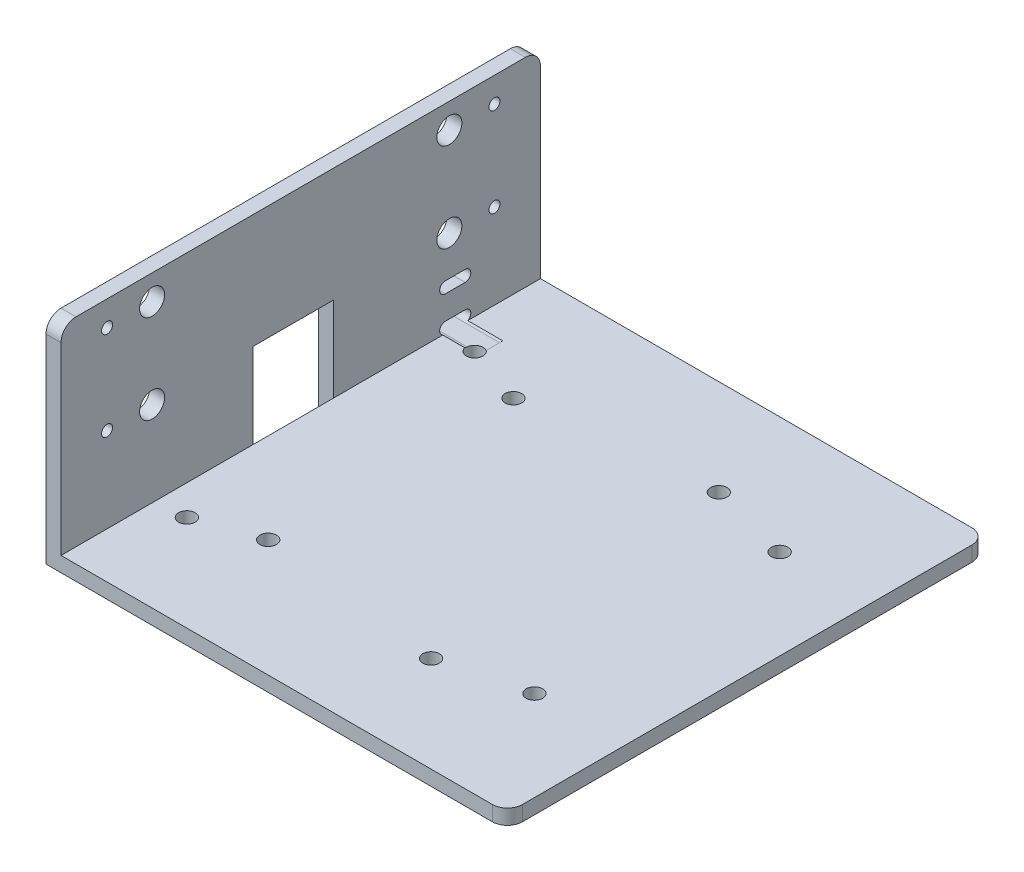
from build123d import *

# Parameters (mm, degrees)
SKETCH_3_W           = 89.2
SKETCH_3_H           = 95.8
SKETCH_3_R           = 1.65
EXTRUDE_1_DEPTH      = 3
EXTRUDE_1_DEPTH_BACK = 0.0001
SKETCH_6_W           = 3
SKETCH_6_H           = 95.8
EXTRUDE_3_DEPTH      = 42.8
SKETCH_8_R           = 1.1
CUT_EXTRUDE_6_DEPTH  = 47.8
SKETCH_8_9_R         = 1.1
CUT_EXTRUDE_7_DEPTH  = 47.8
SKETCH_8_10_R        = 1.1
CUT_EXTRUDE_8_DEPTH  = 47.8
SKETCH_8_11_R        = 1.1
CUT_EXTRUDE_9_DEPTH  = 47.8
SKETCH_12_R          = 2.5
CUT_EXTRUDE_10_DEPTH = 47.8
SKETCH_12_4_R        = 2.5
CUT_EXTRUDE_11_DEPTH = 47.8
CUT_EXTRUDE_21_DEPTH = 19.978934005
SKETCH_16_W          = 3
SKETCH_16_H          = 16.067623689
EXTRUDE_4_DEPTH      = 3
SKETCH_17_W          = 16.067623689
SKETCH_17_H          = 3
CUT_EXTRUDE_22_DEPTH = 3
CUT_EXTRUDE_23_DEPTH = 10
FILLET_1_R           = 3
FILLET_2_R           = 3
FILLET_3_R           = 3
FILLET_4_R           = 3


with BuildPart() as part:
    # Sketch 3 → Extrude 1 (new body, two sides)
    with BuildSketch(Plane(origin=(0, 0, 0), x_dir=(1, 0, 0), z_dir=(0, 1, 0))) as extrude_1_sk:
        with Locations((44.6, -47.9)):
            Rectangle(SKETCH_3_W, SKETCH_3_H)
        with Locations(Location((18, -23.4, 0), (0, 0, 270))):  # turned: the seam where the file's is
            Circle(SKETCH_3_R, mode=Mode.SUBTRACT)
        with Locations(Location((71.2, -23.4, 0), (0, 0, 270))):  # turned: the seam where the file's is
            Circle(SKETCH_3_R, mode=Mode.SUBTRACT)
        with Locations(Location((18, -72.4, 0), (0, 0, 270))):  # turned: the seam where the file's is
            Circle(SKETCH_3_R, mode=Mode.SUBTRACT)
        with Locations(Location((71.2, -72.4, 0), (0, 0, 270))):  # turned: the seam where the file's is
            Circle(SKETCH_3_R, mode=Mode.SUBTRACT)
        with Locations(Location((6, -19.15, 0), (0, 0, 270))):  # turned: the seam where the file's is
            Circle(SKETCH_3_R, mode=Mode.SUBTRACT)
        with Locations(Location((54.8, -19.15, 0), (0, 0, 270))):  # turned: the seam where the file's is
            Circle(SKETCH_3_R, mode=Mode.SUBTRACT)
        with Locations(Location((6, -76.65, 0), (0, 0, 270))):  # turned: the seam where the file's is
            Circle(SKETCH_3_R, mode=Mode.SUBTRACT)
        with Locations(Location((54.8, -76.65, 0), (0, 0, 270))):  # turned: the seam where the file's is
            Circle(SKETCH_3_R, mode=Mode.SUBTRACT)
    extrude(amount=EXTRUDE_1_DEPTH)
    extrude(extrude_1_sk.sketch, amount=-EXTRUDE_1_DEPTH_BACK)

    # Sketch 6 → Extrude 3 (add)
    with BuildSketch(Plane.XZ.offset(0.0001)):
        with Locations((-1.5, 47.9)):
            Rectangle(SKETCH_6_W, SKETCH_6_H)
    extrude(amount=-EXTRUDE_3_DEPTH)

    # Sketch 8 → Cut-Extrude 6 (cut)
    with BuildSketch(Plane.ZY.offset(3)):
        with Locations((86.6, 37.8)):
            Circle(SKETCH_8_R)
    extrude(amount=-CUT_EXTRUDE_6_DEPTH, mode=Mode.SUBTRACT)

    # Sketch 8_9 → Cut-Extrude 7 (cut)
    with BuildSketch(Plane.ZY.offset(3)):
        with Locations((9.2, 37.8)):
            Circle(SKETCH_8_9_R)
    extrude(amount=-CUT_EXTRUDE_7_DEPTH, mode=Mode.SUBTRACT)

    # Sketch 8_10 → Cut-Extrude 8 (cut)
    with BuildSketch(Plane.ZY.offset(3)):
        with Locations((9.2, 20)):
            Circle(SKETCH_8_10_R)
    extrude(amount=-CUT_EXTRUDE_8_DEPTH, mode=Mode.SUBTRACT)

    # Sketch 8_11 → Cut-Extrude 9 (cut)
    with BuildSketch(Plane.ZY.offset(3)):
        with Locations((86.6, 20)):
            Circle(SKETCH_8_11_R)
    extrude(amount=-CUT_EXTRUDE_9_DEPTH, mode=Mode.SUBTRACT)

    # Sketch 12 → Cut-Extrude 10 (cut)
    with BuildSketch(Plane.ZY.offset(3)):
        with Locations((18.2, 37.8)):
            Circle(SKETCH_12_R)
    extrude(amount=-CUT_EXTRUDE_10_DEPTH, mode=Mode.SUBTRACT)

    # Sketch 12_4 → Cut-Extrude 11 (cut)
    with BuildSketch(Plane.ZY.offset(3)):
        with Locations((77.6, 37.8)):
            Circle(SKETCH_12_4_R)
        with Locations((77.6, 20)):
            Circle(SKETCH_12_4_R)
        with Locations((18.2, 37.8)):
            Circle(SKETCH_12_4_R)
        with Locations((18.2, 20)):
            Circle(SKETCH_12_4_R)
    extrude(amount=-CUT_EXTRUDE_11_DEPTH, mode=Mode.SUBTRACT)

    # Sketch 13 → Cut-Extrude 21 (cut)
    with BuildSketch(Plane.XZ.offset(0.0001)):
        Polygon((-5, 47.9), (-5, 57.401139719), (0, 57.401139719), (0, 41.33351603), (-5, 41.33351603), align=None)
    extrude(amount=-CUT_EXTRUDE_21_DEPTH, mode=Mode.SUBTRACT)

    # Sketch 16 → Extrude 4 (add)
    with BuildSketch(Plane.XZ.offset(0.0001)):
        with Locations((-1.5, 49.367327875)):
            Rectangle(SKETCH_16_W, SKETCH_16_H)
    extrude(amount=-EXTRUDE_4_DEPTH)

    # Sketch 17 → Cut-Extrude 22 (cut)
    with BuildSketch(Plane.ZY.offset(3)):
        with Locations((49.367327875, 1.4999)):
            Rectangle(SKETCH_17_W, SKETCH_17_H)
    extrude(amount=-CUT_EXTRUDE_22_DEPTH, mode=Mode.SUBTRACT)

    # Sketch 18 → Cut-Extrude 23 (cut)
    with BuildSketch(Plane.ZY.offset(3)):
        with BuildLine():
            Line((19.009554581, 2.875833037), (15.037851313, 2.875833037))
            ThreePointArc((15.037851313, 2.875833037), (13.91378435, 3.9999), (15.037851313, 5.123966963))
            Line((15.037851313, 5.123966963), (19.009554581, 5.123966963))
            ThreePointArc((19.009554581, 5.123966963), (20.133621543, 3.9999), (19.009554581, 2.875833037))
        make_face()
        with BuildLine():
            Line((15.037851313, 12.123966963), (19.009554581, 12.123966963))
            ThreePointArc((19.009554581, 12.123966963), (20.133621543, 10.9999), (19.009554581, 9.875833037))
            Line((19.009554581, 9.875833037), (15.037851313, 9.875833037))
            ThreePointArc((15.037851313, 9.875833037), (13.91378435, 10.9999), (15.037851313, 12.123966963))
        make_face()
    extrude(amount=-CUT_EXTRUDE_23_DEPTH, mode=Mode.SUBTRACT)

    # Fillet 1
    fillet_1_edges = [part.edges().sort_by_distance(p)[0] for p in [
        (-1.5, 42.7999, 95.8),
    ]]
    fillet(fillet_1_edges, radius=FILLET_1_R)

    # Fillet 2
    fillet_2_edges = [part.edges().sort_by_distance(p)[0] for p in [
        (-1.5, 42.7999, 0),
    ]]
    fillet(fillet_2_edges, radius=FILLET_2_R)

    # Fillet 3
    fillet_3_edges = [part.edges().sort_by_distance(p)[0] for p in [
        (89.2, 1.49995, 95.8),
    ]]
    fillet(fillet_3_edges, radius=FILLET_3_R)

    # Fillet 4
    fillet_4_edges = [part.edges().sort_by_distance(p)[0] for p in [
        (89.2, 1.49995, 0),
    ]]
    fillet(fillet_4_edges, radius=FILLET_4_R)


solid = part.part
